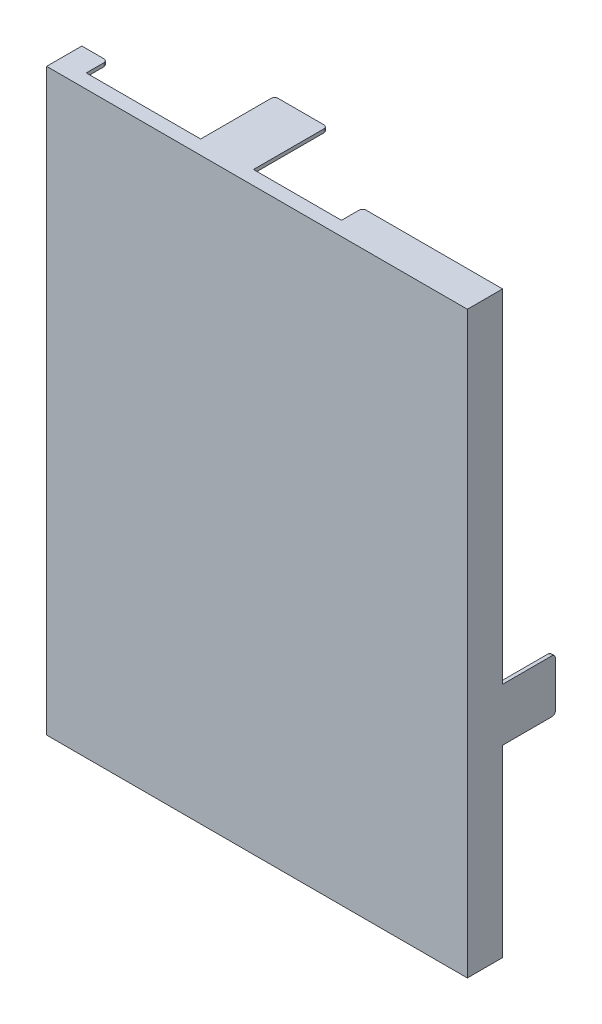
from build123d import *

# Parameters (mm, degrees)
SKETCH_1_W          = 23.9
SKETCH_1_H          = 32.9
EXTRUDE_1_DEPTH     = 2
SHELL_1_T           = -0.2
SKETCH_3_2_W        = 9
SKETCH_3_2_H        = 0.2
SKETCH_3_2_W_2      = 1.2
SKETCH_3_2_W_3      = 5
SKETCH_3_2_W_4      = 6.5
CUT_EXTRUDE_3_DEPTH = 1.2
SKETCH_3_W          = 3
SKETCH_3_H          = 0.2
SKETCH_3_W_2        = 0.2
SKETCH_3_H_2        = 3
EXTRUDE_2_DEPTH     = 3
FILLET_1_R          = 0.2


with BuildPart() as part:
    # Sketch 1 → Extrude 1 (new body)
    with BuildSketch(Plane.XY):
        with Locations((11.8, 16.3)):
            Rectangle(SKETCH_1_W, SKETCH_1_H)
    extrude(amount=EXTRUDE_1_DEPTH)

    # Shell 1
    shell_1_openings = [part.faces().sort_by_distance(p)[0] for p in [
        (11.8, 16.3, 0),
    ]]
    offset(amount=SHELL_1_T, openings=shell_1_openings, kind=Kind.INTERSECTION)

    # Sketch 3_2 → Cut-Extrude 3 (cut)
    with BuildSketch(Plane(origin=(0, 0, 0), x_dir=(-1, 0, 0), z_dir=(0, 0, -1))):
        with Locations((-5.8, -0.05)):
            Rectangle(SKETCH_3_2_W, SKETCH_3_2_H)
        with Locations((-21.7, -0.05)):
            Rectangle(SKETCH_3_2_W_2, SKETCH_3_2_H)
        with Locations((-13.3, 32.65)):
            Rectangle(SKETCH_3_2_W_3, SKETCH_3_2_H)
        with Locations((-4.55, 32.65)):
            Rectangle(SKETCH_3_2_W_4, SKETCH_3_2_H)
    extrude(amount=-CUT_EXTRUDE_3_DEPTH, mode=Mode.SUBTRACT)

    # Sketch 3 → Extrude 2 (add)
    with BuildSketch(Plane(origin=(0, 0, 0), x_dir=(-1, 0, 0), z_dir=(0, 0, -1))):
        with Locations((-9.3, 32.65)):
            Rectangle(SKETCH_3_W, SKETCH_3_H)
        with Locations((-23.65, 11.8)):
            Rectangle(SKETCH_3_W_2, SKETCH_3_H_2)
        with Locations((0.05, 11.8)):
            Rectangle(SKETCH_3_W_2, SKETCH_3_H_2)
    extrude(amount=EXTRUDE_2_DEPTH)

    # Fillet 1
    fillet_1_edges = [part.edges().sort_by_distance(p)[0] for p in [
        (-0.05, 13.3, -3),
        (-0.05, 10.3, -3),
        (23.65, 13.3, -3),
        (23.65, 10.3, -3),
        (1.3, -0.05, 0),
        (10.3, -0.05, 0),
        (21.1, -0.05, 0),
        (22.3, -0.05, 0),
        (15.8, 32.65, 0),
        (1.3, 32.65, 0),
        (7.8, 32.65, -3),
        (10.8, 32.65, -3),
    ]]
    fillet(fillet_1_edges, radius=FILLET_1_R)


solid = part.part
